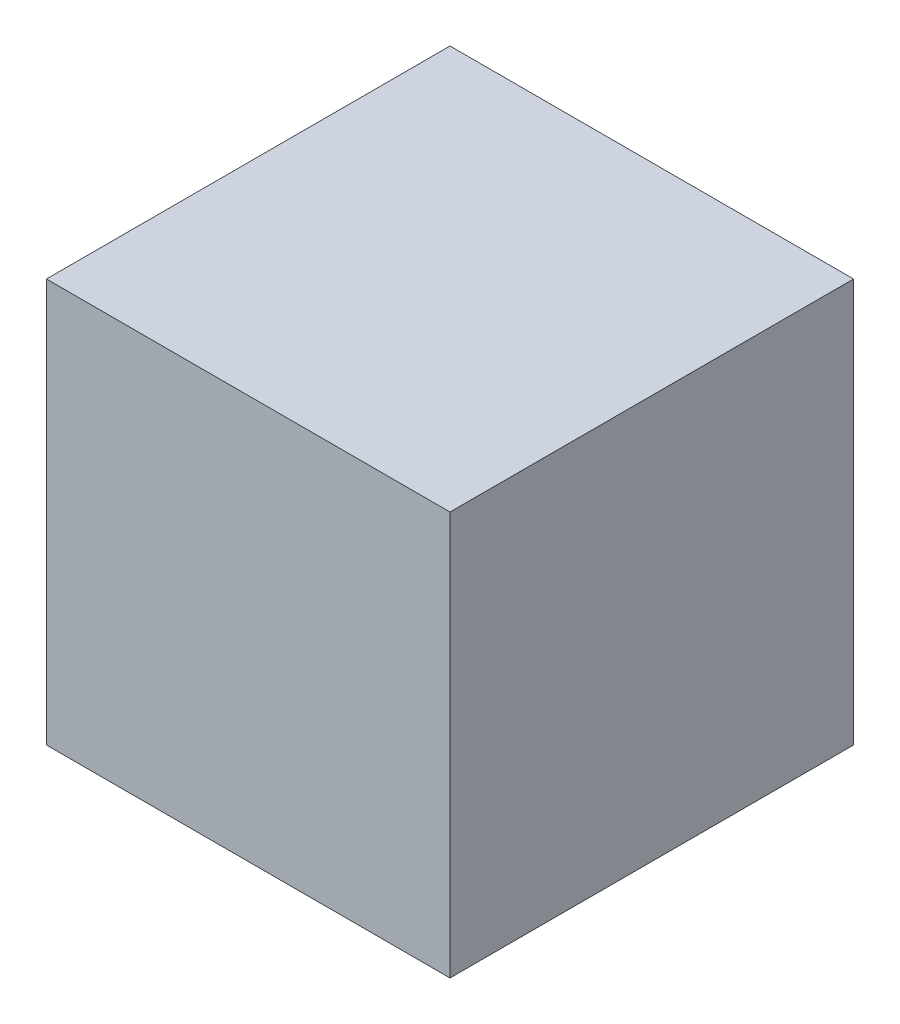
from build123d import *

# Parameters (mm, degrees)
SKETCH1_W           = 27.78125
SKETCH1_H           = 27.78125
BOSS_EXTRUDE1_DEPTH = 27.78125


with BuildPart() as part:
    # Sketch1 → Boss-Extrude1 (new body)
    with BuildSketch(Plane(origin=(0, 0, 0), x_dir=(1, 0, 0), z_dir=(0, 1, 0))):
        Rectangle(SKETCH1_W, SKETCH1_H)
    extrude(amount=BOSS_EXTRUDE1_DEPTH)


solid = part.part
